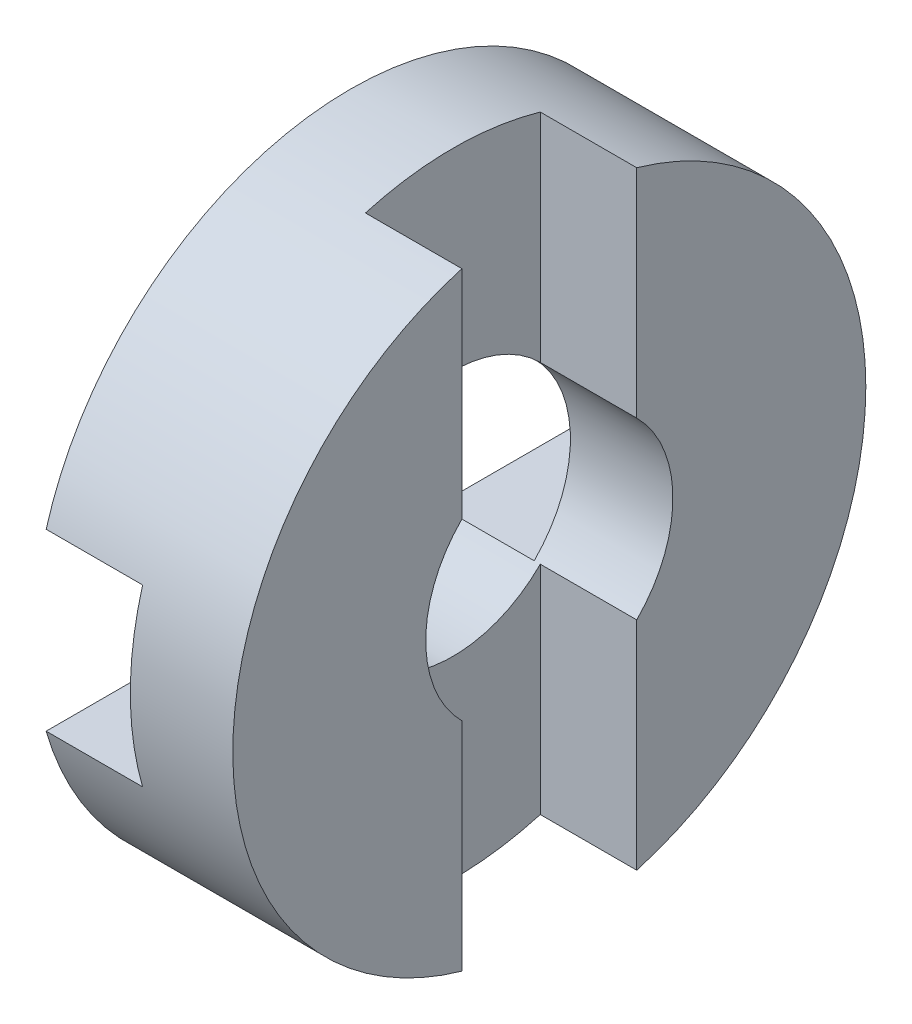
from build123d import *

# Parameters (mm, degrees)
SKETCH1_W               = 6.6
SKETCH1_H               = 6.4
CUT_EXTRUDE1_DEPTH      = 10.5
CUT_EXTRUDE1_DEPTH_BACK = 10.5
SKETCH2_W               = 3.2
SKETCH2_H               = 5.8
CUT_EXTRUDE2_DEPTH      = 10.5
CUT_EXTRUDE2_DEPTH_BACK = 10.5
SKETCH3_W               = 3.2
SKETCH3_H               = 5.8


with BuildPart() as part:
    # Sketch1 → Revolve1 (revolve)
    with BuildSketch(Plane.XY):
        with Locations((3.3, 7.3)):
            Rectangle(SKETCH1_W, SKETCH1_H)
    revolve(axis=Axis((6.6, 0, 0), (-1, 0, 0)))

    # Sketch2 → Cut-Extrude1 (cut, two sides: drawn at the far end of the back side and taken through both)
    with BuildSketch(Plane.XY.offset(-CUT_EXTRUDE1_DEPTH_BACK)):
        with Locations((1.6, 0)):
            Rectangle(SKETCH2_W, SKETCH2_H)
    extrude(amount=CUT_EXTRUDE1_DEPTH + CUT_EXTRUDE1_DEPTH_BACK, mode=Mode.SUBTRACT)

    # Sketch3 → Cut-Extrude2 (cut, two sides: drawn at the far end of the back side and taken through both)
    with BuildSketch(Plane(origin=(0, 0, 0), x_dir=(-1, 0, 0), z_dir=(0, 1, 0)).offset(-CUT_EXTRUDE2_DEPTH_BACK)):
        with Locations((-5, 0)):
            Rectangle(SKETCH3_W, SKETCH3_H)
    extrude(amount=CUT_EXTRUDE2_DEPTH + CUT_EXTRUDE2_DEPTH_BACK, mode=Mode.SUBTRACT)


solid = part.part
